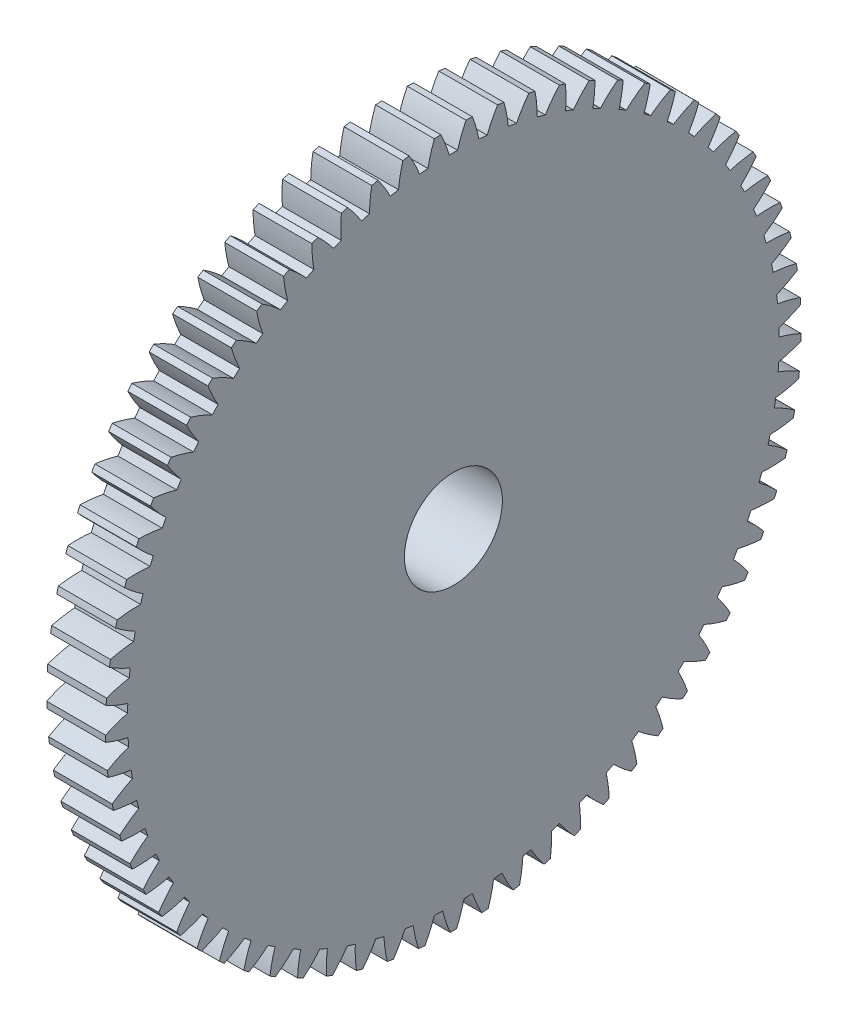
from build123d import *

# Parameters (mm, degrees)
BASPROSKE_W         = 3
BASPROSKE_H         = 17.75
TOOTHCUT_DEPTH      = 26.28092166
TEETHCUTS_COUNT     = 69
TEETHCUTS_ANGLE     = 354.782608696
HUBNEAONESKE_R      = 10
HUBNEARONE_DEPTH    = 2.0000508
BORSKE_R            = 2.5
BORE_DEPTH          = 5.0000508
SKETCH1_R           = 4
SKETCH1_R_2         = 2.5
BOSS_EXTRUDE1_DEPTH = 6


with BuildPart() as part:
    # BasProSke → Base-Revolve (revolve)
    with BuildSketch(Plane(origin=(0, 0, 0), x_dir=(1, 0, 0), z_dir=(0, 1, 0)), mode=Mode.PRIVATE) as base_revolve_sk:
        with Locations((1.5, 8.875)):
            Rectangle(BASPROSKE_W, BASPROSKE_H)
    revolve(base_revolve_sk.sketch.rotate(Axis((-10, 0, 0), (1, 0, 0)), 180), axis=Axis((-10, 0, 0), (1, 0, 0)))

    # TooCutSke → ToothCut (cut, through all)
    with BuildSketch(Plane(origin=(0, 0, 0), x_dir=(0, 0, -1), z_dir=(1, 0, 0))):
        with BuildLine():
            ThreePointArc((0.212442532, 16.622642515), (0, 16.624), (-0.212442532, 16.622642515))
            ThreePointArc((-0.212442532, 16.622642515), (-0.409416757, 17.20282737), (-0.657083146, 17.763251023))
            ThreePointArc((-0.657083146, 17.763251023), (0, 17.7754), (0.657083146, 17.763251023))
            ThreePointArc((0.657083146, 17.763251023), (0.409416757, 17.20282737), (0.212442532, 16.622642515))
        make_face()
    toothcut = extrude(amount=TOOTHCUT_DEPTH, mode=Mode.SUBTRACT)

    # TeethCuts: ToothCut ×69 about axis
    teethcuts_axis = Axis((-10, 0, 0), (1, 0, 0))
    for i in range(1, TEETHCUTS_COUNT):
        add(toothcut.rotate(teethcuts_axis, i * TEETHCUTS_ANGLE / (TEETHCUTS_COUNT - 1)), mode=Mode.SUBTRACT)

    # HubNeaOneSke → HubNearOne (add)
    with BuildSketch(Plane.ZY):
        with Locations(Location((0, 0, 0), (0, 0, 180))):
            Circle(HUBNEAONESKE_R)
    extrude(amount=HUBNEARONE_DEPTH)

    # BorSke → Bore (cut, symmetric)
    with BuildSketch(Plane(origin=(0, 0, 0), x_dir=(0, 0, -1), z_dir=(1, 0, 0))):
        with Locations(Location((0, 0, 0), (0, 0, 180))):
            Circle(BORSKE_R)
    extrude(amount=BORE_DEPTH, both=True, mode=Mode.SUBTRACT)

    # Sketch1 → Boss-Extrude1 (add)
    with BuildSketch(Plane.ZY.offset(2.0000508)):
        Circle(SKETCH1_R)
        Circle(SKETCH1_R_2, mode=Mode.SUBTRACT)
    extrude(amount=BOSS_EXTRUDE1_DEPTH)


solid = part.part
